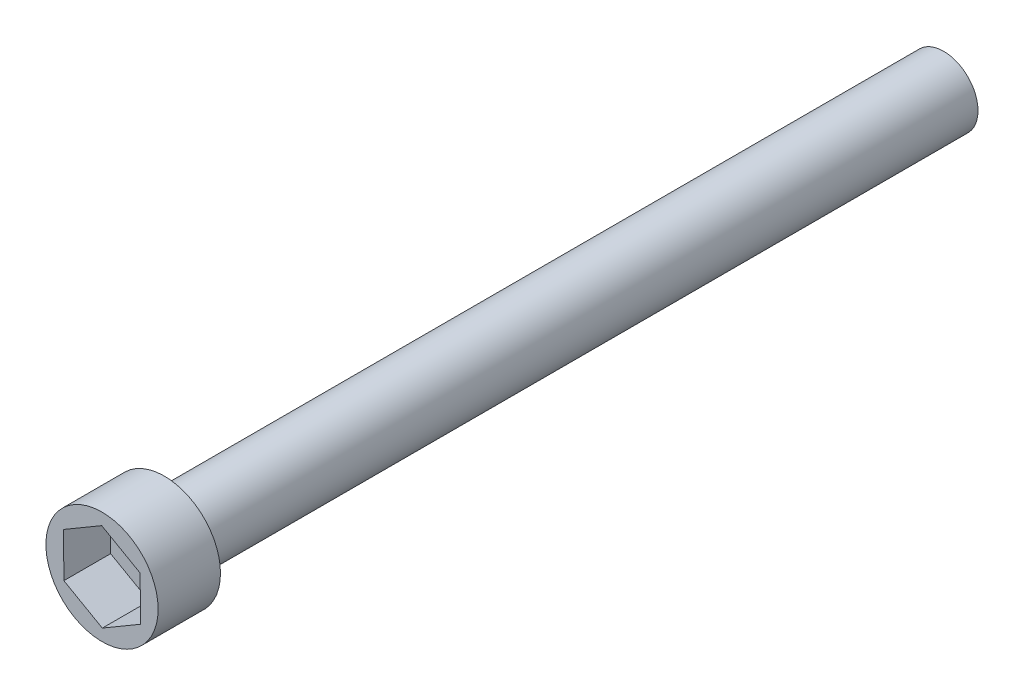
from build123d import *

# Parameters (mm, degrees)
SKETCH1_R           = 1.397
BOSS_EXTRUDE1_DEPTH = 31.75
SKETCH2_R           = 2.286
BOSS_EXTRUDE2_DEPTH = 2.54
CUT_EXTRUDE1_DEPTH  = 1.905


with BuildPart() as part:
    # Sketch1 → Boss-Extrude1 (new body)
    with BuildSketch(Plane.XY):
        Circle(SKETCH1_R)
    extrude(amount=BOSS_EXTRUDE1_DEPTH)

    # Sketch2 → Boss-Extrude2 (add)
    with BuildSketch(Plane.XY.offset(31.75)):
        Circle(SKETCH2_R)
    extrude(amount=BOSS_EXTRUDE2_DEPTH)

    # Sketch4 → Cut-Extrude1 (cut)
    with BuildSketch(Plane.XY.offset(34.29)):
        Polygon((1.566413347, -0.889919011), (1.553899145, 0.911594246), (-0.012514203, 1.801513257), (-1.566413347, 0.889919011), (-1.553899145, -0.911594246), (0.012514203, -1.801513257), align=None)
    extrude(amount=-CUT_EXTRUDE1_DEPTH, mode=Mode.SUBTRACT)


solid = part.part
